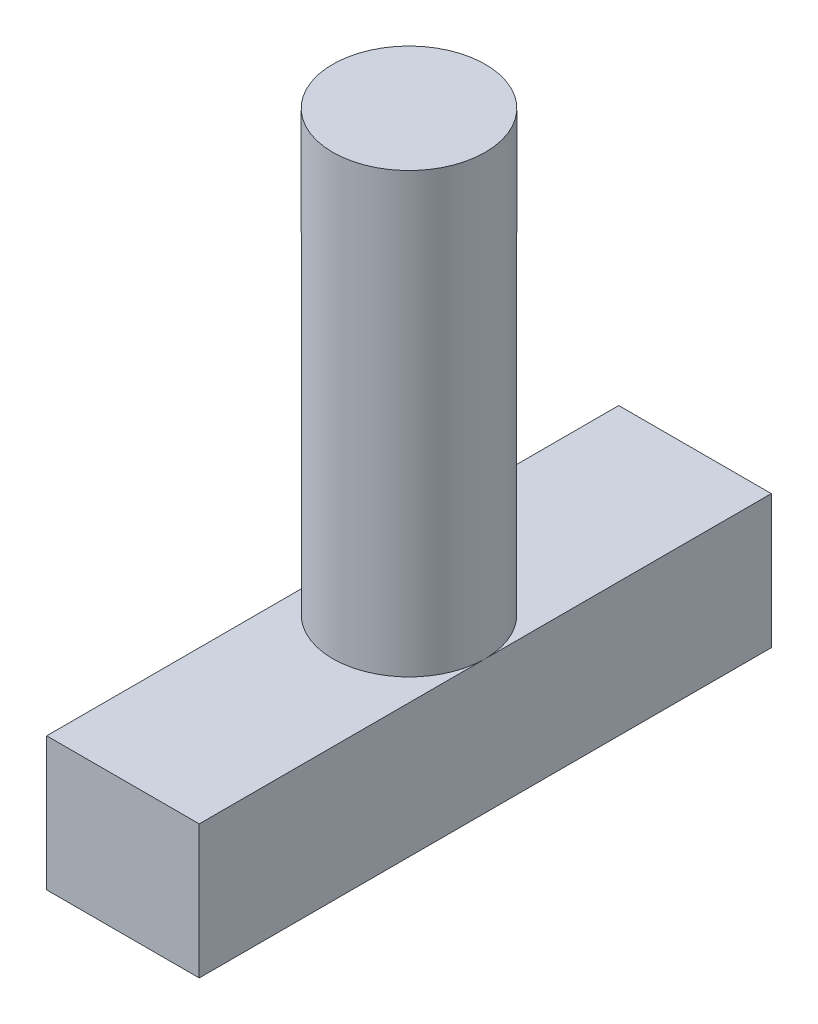
from build123d import *

# Parameters (mm, degrees)
CROQUIS1_R              = 2
SALIENTE_EXTRUIR1_DEPTH = 15
CROQUIS2_W              = 4
CROQUIS2_H              = 15
SALIENTE_EXTRUIR2_DEPTH = 3.5


with BuildPart() as part:
    # Croquis1 → Saliente-Extruir1 (new body)
    with BuildSketch(Plane(origin=(0, 0, 0), x_dir=(1, 0, 0), z_dir=(0, 1, 0))):
        Circle(CROQUIS1_R)
    extrude(amount=SALIENTE_EXTRUIR1_DEPTH)

    # Croquis2 → Saliente-Extruir2 (add)
    with BuildSketch(Plane(origin=(0, 0, 0), x_dir=(1, 0, 0), z_dir=(0, 1, 0))):
        Rectangle(CROQUIS2_W, CROQUIS2_H)
    extrude(amount=SALIENTE_EXTRUIR2_DEPTH)


solid = part.part
